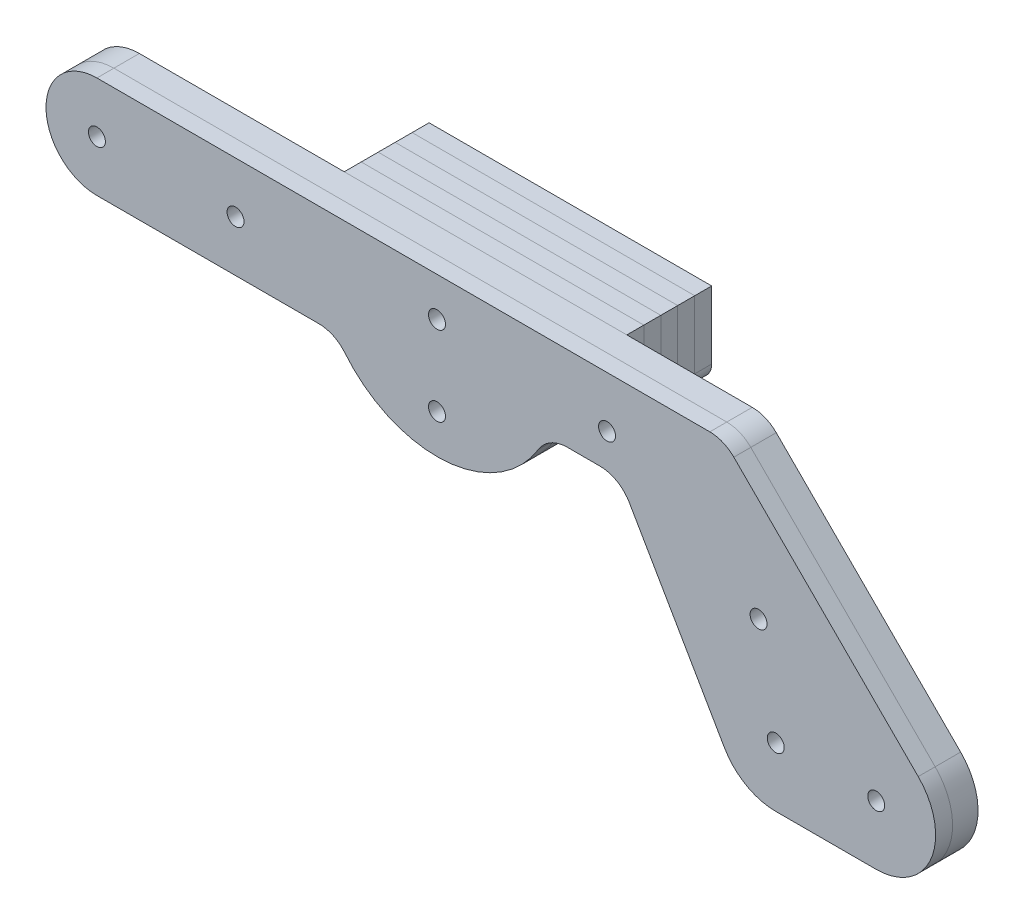
from build123d import *

# Parameters (mm, degrees)
SKETCH2_R           = 6.35
BOSS_EXTRUDE1_DEPTH = 9.525
FILLET1_R           = 12.7
SKETCH3_R           = 3.175
BOSS_EXTRUDE2_DEPTH = 6.35
SKETCH5_R           = 6.35
BOSS_EXTRUDE4_DEPTH = 6.35
LPATTERN1_COUNT     = 5
LPATTERN1_PITCH     = 6.35


with BuildPart() as part:
    # Sketch2 → Boss-Extrude1 (new body)
    with BuildSketch(Plane.XY):
        with BuildLine():
            Line((0, 177.33399408), (234.588550395, 177.33399408))
            Line((234.588550395, 177.33399408), (307.307096264, 104.615448212))
            ThreePointArc((307.307096264, 104.615448212), (312.124870662, 80.394860716), (291.591648052, 66.675))
            Line((291.591648052, 66.675), (254, 66.675))
            ThreePointArc((254, 66.675), (242.8875, 69.652585401), (234.752585401, 77.7875))
            Line((234.752585401, 77.7875), (195.559880595, 145.67125601))
            Line((195.559880595, 145.67125601), (168.303741698, 145.67125601))
            ThreePointArc((168.303741698, 145.67125601), (130.869664436, 118.410686866), (89.507379112, 139.23399408))
            Line((89.507379112, 139.23399408), (0, 139.23399408))
            ThreePointArc((0, 139.23399408), (-19.05, 158.28399408), (0, 177.33399408))
        make_face()
        with Locations((254, 88.9)):
            Circle(SKETCH2_R, mode=Mode.SUBTRACT)
        with Locations((0, 158.28399408)):
            Circle(SKETCH2_R, mode=Mode.SUBTRACT)
        with Locations((291.591648052, 88.9)):
            Circle(SKETCH2_R, mode=Mode.SUBTRACT)
        with Locations((51.860500376, 158.28399408)):
            Circle(SKETCH2_R, mode=Mode.SUBTRACT)
        with Locations((127.250383148, 162.713094284)):
            Circle(SKETCH2_R, mode=Mode.SUBTRACT)
        with Locations((190.863687454, 158.28399408)):
            Circle(SKETCH2_R, mode=Mode.SUBTRACT)
        with Locations((247.572577113, 125.755777395)):
            Circle(SKETCH2_R, mode=Mode.SUBTRACT)
        with Locations((127.250383148, 132.88399408)):
            Circle(SKETCH2_R, mode=Mode.SUBTRACT)
    extrude(amount=BOSS_EXTRUDE1_DEPTH)

    # Fillet1
    fillet1_edges = [part.edges().sort_by_distance(p)[0] for p in [
        (195.559880595, 145.67125601, 4.7625),
        (168.303741698, 145.67125601, 4.7625),
        (89.507379112, 139.23399408, 4.7625),
        (234.588550395, 177.33399408, 4.7625),
    ]]
    fillet(fillet1_edges, radius=FILLET1_R)


with BuildPart() as body_2:
    # Sketch3 → Boss-Extrude2 (new body)
    with BuildSketch(Plane.XY.offset(9.525)):
        with BuildLine():
            Line((0, 139.23399408), (83.010184138, 139.23399408))
            ThreePointArc((83.010184138, 139.23399408), (88.450061867, 138.009957233), (92.841339473, 134.573794125))
            ThreePointArc((92.841339473, 134.573794125), (130.31841803, 118.369101884), (165.206779874, 139.580553404))
            ThreePointArc((165.206779874, 139.580553404), (169.832464609, 144.044378355), (176.051464653, 145.67125601))
            Line((176.051464653, 145.67125601), (188.227532176, 145.67125601))
            ThreePointArc((188.227532176, 145.67125601), (194.577532176, 143.969778638), (199.226054804, 139.32125601))
            Line((199.226054804, 139.32125601), (234.752585401, 77.7875))
            ThreePointArc((234.752585401, 77.7875), (242.8875, 69.652585401), (254, 66.675))
            Line((254, 66.675), (291.591648052, 66.675))
            ThreePointArc((291.591648052, 66.675), (312.124870662, 80.394860716), (307.307096264, 104.615448212))
            Line((307.307096264, 104.615448212), (238.308294274, 173.614250201))
            ThreePointArc((238.308294274, 173.614250201), (234.188117744, 176.367264143), (229.328038153, 177.33399408))
            Line((229.328038153, 177.33399408), (0, 177.33399408))
            ThreePointArc((0, 177.33399408), (-19.05, 158.28399408), (0, 139.23399408))
        make_face()
        with Locations((0, 158.28399408)):
            Circle(SKETCH3_R, mode=Mode.SUBTRACT)
        with Locations((254, 88.9)):
            Circle(SKETCH3_R, mode=Mode.SUBTRACT)
        with Locations((291.591648052, 88.9)):
            Circle(SKETCH3_R, mode=Mode.SUBTRACT)
        with Locations((51.860500376, 158.28399408)):
            Circle(SKETCH3_R, mode=Mode.SUBTRACT)
        with Locations((127.250383148, 162.713094284)):
            Circle(SKETCH3_R, mode=Mode.SUBTRACT)
        with Locations((190.863687454, 158.28399408)):
            Circle(SKETCH3_R, mode=Mode.SUBTRACT)
        with Locations((247.572577113, 125.755777395)):
            Circle(SKETCH3_R, mode=Mode.SUBTRACT)
        with Locations((127.250383148, 132.88399408)):
            Circle(SKETCH3_R, mode=Mode.SUBTRACT)
    extrude(amount=BOSS_EXTRUDE2_DEPTH)


with BuildPart() as body_3:
    # Sketch5 → Boss-Extrude4 (new body)
    with BuildSketch(Plane(origin=(0, 0, 0), x_dir=(-1, 0, 0), z_dir=(0, 0, -1))):
        with BuildLine():
            Line((-182.401464653, 152.02125601), (-182.401464653, 177.33399408))
            Line((-182.401464653, 177.33399408), (-76.660184138, 177.33399408))
            Line((-76.660184138, 177.33399408), (-76.660184138, 145.58399408))
            ThreePointArc((-76.660184138, 145.58399408), (-78.520056077, 141.09386602), (-83.010184138, 139.23399408))
            ThreePointArc((-83.010184138, 139.23399408), (-88.450061867, 138.009957233), (-92.841339473, 134.573794125))
            ThreePointArc((-92.841339473, 134.573794125), (-130.31841803, 118.369101884), (-165.206779874, 139.580553404))
            ThreePointArc((-165.206779874, 139.580553404), (-169.832464609, 144.044378355), (-176.051464653, 145.67125601))
            ThreePointArc((-176.051464653, 145.67125601), (-180.541592714, 147.53112795), (-182.401464653, 152.02125601))
        make_face()
        with Locations((-127.250383148, 162.713094284)):
            Circle(SKETCH5_R, mode=Mode.SUBTRACT)
        with Locations((-127.250383148, 132.88399408)):
            Circle(SKETCH5_R, mode=Mode.SUBTRACT)
    extrude(amount=BOSS_EXTRUDE4_DEPTH)


with BuildPart() as lpattern1_1:
    # LPattern1: pattern copy
    add(body_3.part.moved(Location(Vector(0, 0, -1) * (1 * LPATTERN1_PITCH))))


with BuildPart() as lpattern1_2:
    # LPattern1: pattern copy
    add(body_3.part.moved(Location(Vector(0, 0, -1) * (2 * LPATTERN1_PITCH))))


with BuildPart() as lpattern1_3:
    # LPattern1: pattern copy
    add(body_3.part.moved(Location(Vector(0, 0, -1) * (3 * LPATTERN1_PITCH))))


with BuildPart() as lpattern1_4:
    # LPattern1: pattern copy
    add(body_3.part.moved(Location(Vector(0, 0, -1) * (4 * LPATTERN1_PITCH))))


solid = Compound([part.part, body_2.part, body_3.part, lpattern1_1.part, lpattern1_2.part, lpattern1_3.part, lpattern1_4.part])
